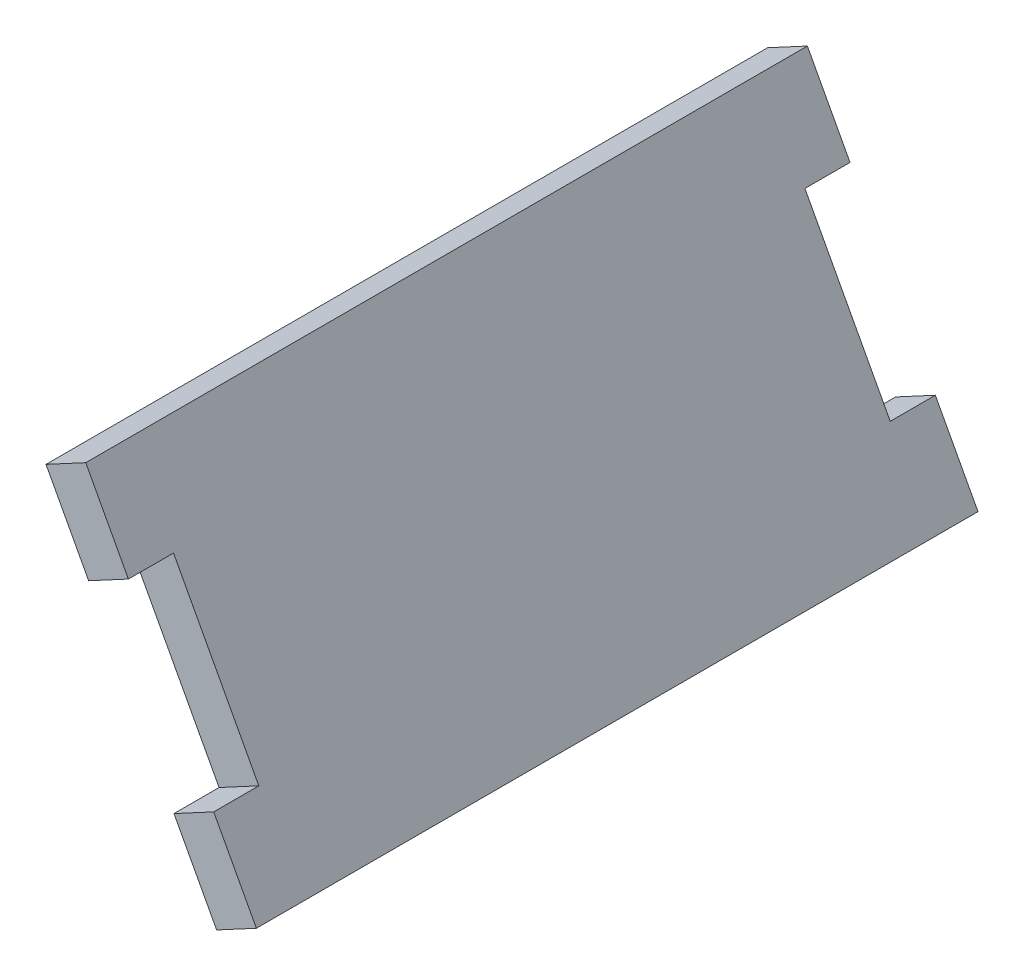
from build123d import *

# Parameters (mm, degrees)
BOSS_EXTRUDE1_DEPTH = 50.8
SKETCH2_W           = 3.175
SKETCH2_H           = 12.7
CUT_EXTRUDE1_DEPTH  = 3.175


with BuildPart() as part:
    # Sketch1 → Boss-Extrude1 (new body)
    with BuildSketch(Plane.XY):
        Polygon((149.508778743, 324.252219732), (161.520244892, 301.871766633), (158.722688254, 300.370333364), (146.711222105, 322.750786464), align=None)
    extrude(amount=-BOSS_EXTRUDE1_DEPTH)

    # Sketch2 → Cut-Extrude1 (cut)
    with BuildSketch(Plane(origin=(251.182349997, 134.808186445, 0), x_dir=(0, 0, -1), z_dir=(0.881120201, 0.472892368, 0))):
        with Locations((1.5875, 202.303620527)):
            Rectangle(SKETCH2_W, SKETCH2_H)
        with Locations((49.2125, 202.303620527)):
            Rectangle(SKETCH2_W, SKETCH2_H)
    extrude(amount=-CUT_EXTRUDE1_DEPTH, mode=Mode.SUBTRACT)


solid = part.part
